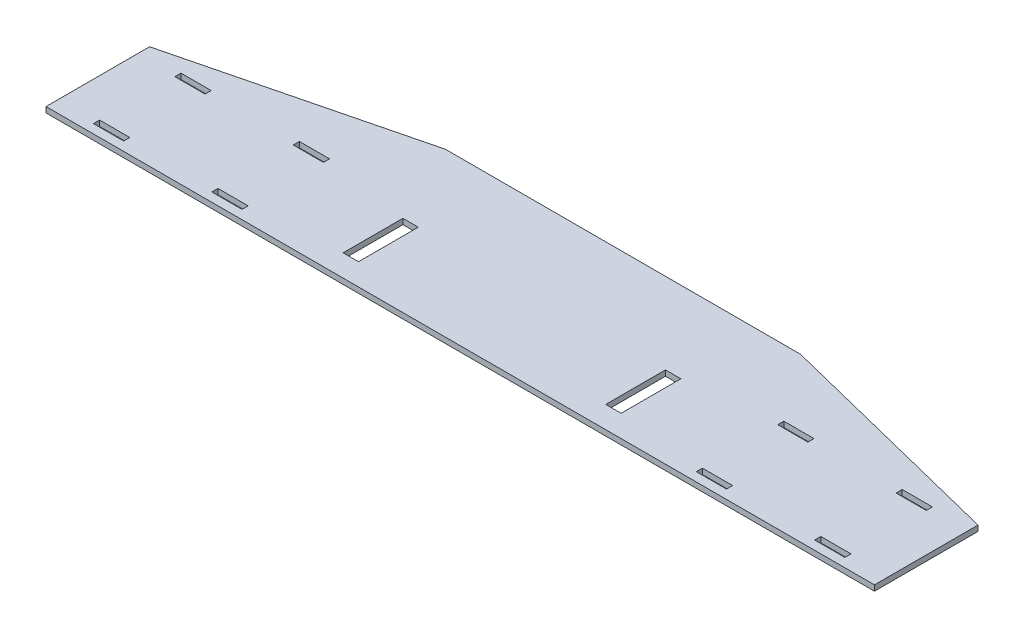
from build123d import *

# Parameters (mm, degrees)
SKETCH1_W           = 711.2
SKETCH1_H           = 139.7
BOSS_EXTRUDE1_DEPTH = 4.7625
CUT_EXTRUDE1_DEPTH  = 5.7625
SKETCH3_W           = 13.208
SKETCH3_H           = 51.308
CUT_EXTRUDE2_DEPTH  = 5.7625
SKETCH4_W           = 25.908
SKETCH4_H           = 5.2705
CUT_EXTRUDE3_DEPTH  = 5.7625


with BuildPart() as part:
    # Sketch1 → Boss-Extrude1 (new body)
    with BuildSketch(Plane(origin=(0, 0, 0), x_dir=(1, 0, 0), z_dir=(0, 1, 0))):
        with Locations((0, 69.85)):
            Rectangle(SKETCH1_W, SKETCH1_H)
    extrude(amount=BOSS_EXTRUDE1_DEPTH)

    # Sketch2 → Cut-Extrude1 (cut, through all)
    with BuildSketch(Plane(origin=(0, 4.7625, 0), x_dir=(1, 0, 0), z_dir=(0, 1, 0))):
        Polygon((-355.6, 88.9), (-152.4, 139.7), (-355.6, 139.7), align=None)
        Polygon((355.6, 139.7), (152.4, 139.7), (355.6, 88.9), align=None)
    extrude(amount=-CUT_EXTRUDE1_DEPTH, mode=Mode.SUBTRACT)

    # Sketch3 → Cut-Extrude2 (cut, through all)
    with BuildSketch(Plane(origin=(0, 0, 0), x_dir=(-1, 0, 0), z_dir=(0, -1, 0))):
        with Locations((-112.7125, 44.45)):
            Rectangle(SKETCH3_W, SKETCH3_H)
        with Locations((112.7125, 44.45)):
            Rectangle(SKETCH3_W, SKETCH3_H)
    extrude(amount=-CUT_EXTRUDE2_DEPTH, mode=Mode.SUBTRACT)

    # Sketch4 → Cut-Extrude3 (cut, through all)
    with BuildSketch(Plane.XZ):
        with Locations((-207.9625, -10.31875)):
            Rectangle(SKETCH4_W, SKETCH4_H)
        with Locations((-207.9625, -80.16875)):
            Rectangle(SKETCH4_W, SKETCH4_H)
        with Locations((-309.5625, -80.16875)):
            Rectangle(SKETCH4_W, SKETCH4_H)
        with Locations((-309.5625, -10.31875)):
            Rectangle(SKETCH4_W, SKETCH4_H)
        with Locations((207.9625, -80.16875)):
            Rectangle(SKETCH4_W, SKETCH4_H)
        with Locations((309.5625, -80.16875)):
            Rectangle(SKETCH4_W, SKETCH4_H)
        with Locations((309.5625, -10.31875)):
            Rectangle(SKETCH4_W, SKETCH4_H)
        with Locations((207.9625, -10.31875)):
            Rectangle(SKETCH4_W, SKETCH4_H)
    extrude(amount=-CUT_EXTRUDE3_DEPTH, mode=Mode.SUBTRACT)


solid = part.part
